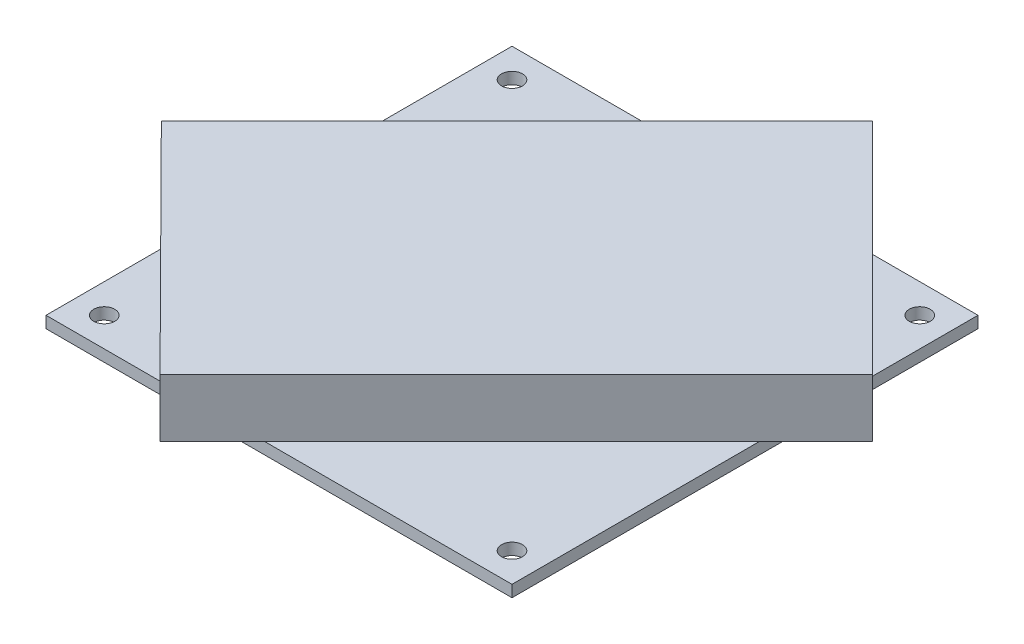
from build123d import *

# Parameters (mm, degrees)
SKETCH1_W              = 80
SKETCH1_H              = 80
PCB_DEPTH              = 2
SKETCH2_R              = 1.8
ATTACHMENT_HOLES_DEPTH = 3
LPATTERN1_COUNT        = 2
LPATTERN1_PITCH        = 70
LPATTERN1_COUNT_DIR2   = 2
LPATTERN1_PITCH_DIR2   = 70
IDUINO_DEPTH           = 10


with BuildPart() as part:
    # Sketch1 → PCB (new body)
    with BuildSketch(Plane(origin=(0, 0, 0), x_dir=(1, 0, 0), z_dir=(0, 1, 0))):
        with Locations((40, 40)):
            Rectangle(SKETCH1_W, SKETCH1_H)
    extrude(amount=PCB_DEPTH)

    # Sketch2 → Attachment Holes (cut, through all)
    with BuildSketch(Plane(origin=(0, 2, 0), x_dir=(1, 0, 0), z_dir=(0, 1, 0))):
        with Locations((5, 75)):
            Circle(SKETCH2_R)
    attachment_holes = extrude(amount=-ATTACHMENT_HOLES_DEPTH, mode=Mode.SUBTRACT)

    # LPattern1: Attachment Holes 2 × 2
    with Locations(*[(i * LPATTERN1_PITCH, 0, j * LPATTERN1_PITCH_DIR2) for i in range(LPATTERN1_COUNT) for j in range(LPATTERN1_COUNT_DIR2) if (i, j) != (0, 0)]):
        add(attachment_holes, mode=Mode.SUBTRACT)

    # Sketch3 → Iduino (add)
    with BuildSketch(Plane(origin=(0, 2, 0), x_dir=(1, 0, 0), z_dir=(0, 1, 0))):
        Polygon((-9, 28.800714626), (52.023315216, 89.824029842), (89.711939971, 52.135405088), (28.576534883, -9), align=None)
    extrude(amount=IDUINO_DEPTH)


solid = part.part
